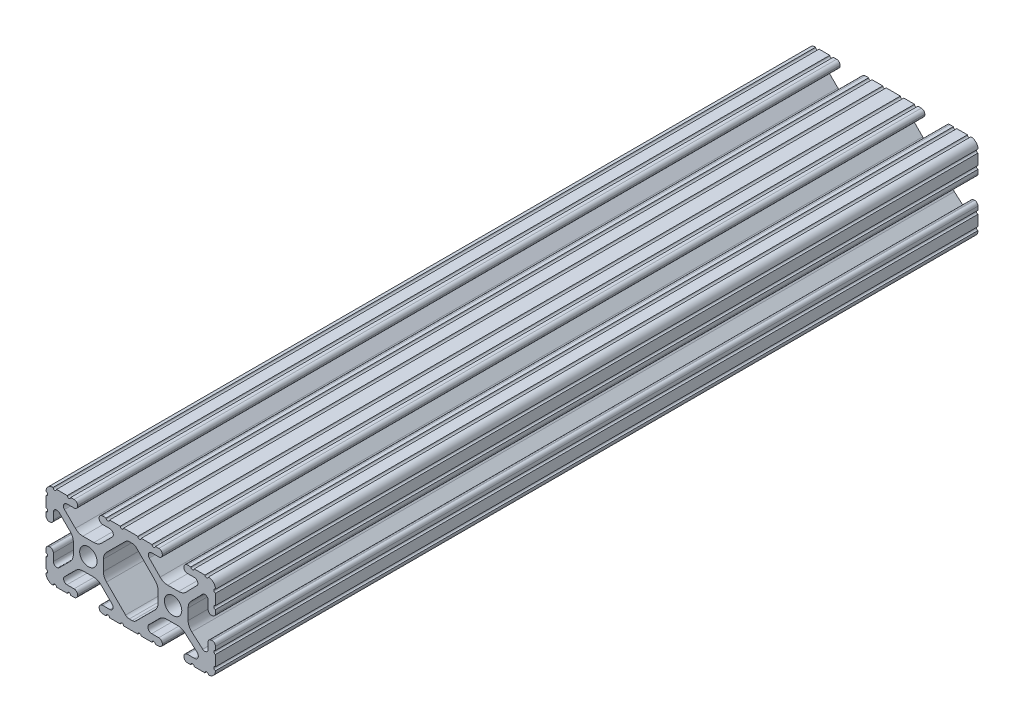
from build123d import *

# Parameters (mm, degrees)
SKETCH1_R           = 2.6035
BOSS_EXTRUDE1_DEPTH = 114.3


with BuildPart() as part:
    # Sketch1 → Boss-Extrude1 (new body, symmetric)
    with BuildSketch(Plane.XY):
        with BuildLine():
            Line((18.01710265, 12.7), (16.98745015, 12.7))
            ThreePointArc((16.98745015, 12.7), (16.245730386, 12.392769614), (15.9385, 11.65104985))
            Line((15.9385, 11.65104985), (15.9385, 11.53922))
            ThreePointArc((15.9385, 11.53922), (16.245750844, 10.797450844), (16.98752, 10.4902))
            Line((16.98752, 10.4902), (19.116384363, 10.4902))
            ThreePointArc((19.116384363, 10.4902), (20.052502933, 9.869096983), (19.844087081, 8.765172272))
            Line((19.844087081, 8.765172272), (16.618993479, 5.455112286))
            ThreePointArc((16.618993479, 5.455112286), (15.578994274, 4.745442459), (14.344932584, 4.4958))
            Line((14.344932584, 4.4958), (11.083317835, 4.4958))
            ThreePointArc((11.083317835, 4.4958), (9.854330953, 4.743306833), (8.816955189, 5.447238587))
            Line((8.816955189, 5.447238587), (5.564154119, 8.762652677))
            ThreePointArc((5.564154119, 8.762652677), (5.352591412, 9.867473037), (6.289393385, 10.4902))
            Line((6.289393385, 10.4902), (8.41248, 10.4902))
            ThreePointArc((8.41248, 10.4902), (9.154249156, 10.797450844), (9.4615, 11.53922))
            Line((9.4615, 11.53922), (9.4615, 11.65104985))
            ThreePointArc((9.4615, 11.65104985), (9.154269614, 12.392769614), (8.41254985, 12.7))
            Line((8.41254985, 12.7), (7.38288465, 12.7))
            ThreePointArc((7.38288465, 12.7), (6.87488465, 12.192), (6.36688465, 12.7))
            Line((6.36688465, 12.7), (3.14958095, 12.7))
            ThreePointArc((3.14958095, 12.7), (2.64158095, 12.192), (2.13358095, 12.7))
            Line((2.13358095, 12.7), (-2.13358095, 12.7))
            ThreePointArc((-2.13358095, 12.7), (-2.64158095, 12.192), (-3.14958095, 12.7))
            Line((-3.14958095, 12.7), (-6.36689735, 12.7))
            ThreePointArc((-6.36689735, 12.7), (-6.87489735, 12.192), (-7.38289735, 12.7))
            Line((-7.38289735, 12.7), (-8.41254985, 12.7))
            ThreePointArc((-8.41254985, 12.7), (-9.154269614, 12.392769614), (-9.4615, 11.65104985))
            Line((-9.4615, 11.65104985), (-9.4615, 11.53922))
            ThreePointArc((-9.4615, 11.53922), (-9.154249156, 10.797450844), (-8.41248, 10.4902))
            Line((-8.41248, 10.4902), (-6.283641037, 10.4902))
            ThreePointArc((-6.283641037, 10.4902), (-5.297291557, 9.829633109), (-5.532576693, 8.666071843))
            Line((-5.532576693, 8.666071843), (-8.809985098, 5.416263103))
            ThreePointArc((-8.809985098, 5.416263103), (-9.836720513, 4.734920264), (-11.045536121, 4.4958))
            Line((-11.045536121, 4.4958), (-14.354463879, 4.4958))
            ThreePointArc((-14.354463879, 4.4958), (-15.563279487, 4.734920264), (-16.590014902, 5.416263103))
            Line((-16.590014902, 5.416263103), (-19.867423307, 8.666071843))
            ThreePointArc((-19.867423307, 8.666071843), (-20.102708443, 9.829633109), (-19.116358963, 10.4902))
            Line((-19.116358963, 10.4902), (-16.98752, 10.4902))
            ThreePointArc((-16.98752, 10.4902), (-16.245750844, 10.797450844), (-15.9385, 11.53922))
            Line((-15.9385, 11.53922), (-15.9385, 11.65104985))
            ThreePointArc((-15.9385, 11.65104985), (-16.245730386, 12.392769614), (-16.98745015, 12.7))
            Line((-16.98745015, 12.7), (-18.01711535, 12.7))
            ThreePointArc((-18.01711535, 12.7), (-18.52511535, 12.192), (-19.03311535, 12.7))
            Line((-19.03311535, 12.7), (-22.2504, 12.7))
            ThreePointArc((-22.2504, 12.7), (-22.758323491, 12.192000006), (-23.266399977, 12.699846982))
            ThreePointArc((-23.266399977, 12.699846982), (-24.782522516, 12.082522516), (-25.399846982, 10.566399977))
            ThreePointArc((-25.399846982, 10.566399977), (-24.892000006, 10.058323491), (-25.4, 9.5504))
            Line((-25.4, 9.5504), (-25.4, 6.3330836))
            ThreePointArc((-25.4, 6.3330836), (-24.892, 5.8250836), (-25.4, 5.3170836))
            Line((-25.4, 5.3170836), (-25.4, 4.237520184))
            ThreePointArc((-25.4, 4.237520184), (-25.107393763, 3.531106237), (-24.400979816, 3.2385))
            Line((-24.400979816, 3.2385), (-24.23922, 3.2385))
            ThreePointArc((-24.23922, 3.2385), (-23.497450844, 3.545750844), (-23.1902, 4.28752))
            Line((-23.1902, 4.28752), (-23.1902, 6.334741132))
            ThreePointArc((-23.1902, 6.334741132), (-22.556026952, 7.286023527), (-21.434002553, 7.066535717))
            Line((-21.434002553, 7.066535717), (-18.147950853, 3.808156468))
            ThreePointArc((-18.147950853, 3.808156468), (-17.452759693, 2.774838327), (-17.208501877, 1.553619571))
            Line((-17.208501877, 1.553619571), (-17.208501877, -1.695179196))
            ThreePointArc((-17.208501877, -1.695179196), (-17.450738657, -2.911536421), (-18.140486065, -3.942289578))
            Line((-18.140486065, -3.942289578), (-21.431579576, -7.227386226))
            ThreePointArc((-21.431579576, -7.227386226), (-22.55444896, -7.449940594), (-23.1902, -6.498002195))
            Line((-23.1902, -6.498002195), (-23.1902, -4.28752))
            ThreePointArc((-23.1902, -4.28752), (-23.497450844, -3.545750844), (-24.23922, -3.2385))
            Line((-24.23922, -3.2385), (-24.35098, -3.2385))
            ThreePointArc((-24.35098, -3.2385), (-25.092749156, -3.545750844), (-25.4, -4.28752))
            Line((-25.4, -4.28752), (-25.4, -5.3171344))
            ThreePointArc((-25.4, -5.3171344), (-24.892, -5.8251344), (-25.4, -6.3331344))
            Line((-25.4, -6.3331344), (-25.4, -9.5504))
            ThreePointArc((-25.4, -9.5504), (-24.892000006, -10.058323491), (-25.399846982, -10.566399977))
            ThreePointArc((-25.399846982, -10.566399977), (-24.782522516, -12.082522516), (-23.266399977, -12.699846982))
            ThreePointArc((-23.266399977, -12.699846982), (-22.758323491, -12.192000006), (-22.2504, -12.7))
            Line((-22.2504, -12.7), (-19.03308995, -12.7))
            ThreePointArc((-19.03308995, -12.7), (-18.52508995, -12.192), (-18.01708995, -12.7))
            Line((-18.01708995, -12.7), (-16.9874692, -12.7))
            ThreePointArc((-16.9874692, -12.7), (-16.245700044, -12.392749156), (-15.9384492, -11.65098))
            Line((-15.9384492, -11.65098), (-15.9384492, -11.53922))
            ThreePointArc((-15.9384492, -11.53922), (-16.245700044, -10.797450844), (-16.9874692, -10.4902))
            Line((-16.9874692, -10.4902), (-19.116358963, -10.4902))
            ThreePointArc((-19.116358963, -10.4902), (-20.055197748, -9.862578342), (-19.834124023, -8.755124678))
            Line((-19.834124023, -8.755124678), (-16.49660751, -5.423689618))
            ThreePointArc((-16.49660751, -5.423689618), (-15.467274017, -4.736928798), (-14.253591699, -4.4958))
            Line((-14.253591699, -4.4958), (-11.146408301, -4.4958))
            ThreePointArc((-11.146408301, -4.4958), (-9.932725983, -4.736928798), (-8.90339249, -5.423689618))
            Line((-8.90339249, -5.423689618), (-5.565875977, -8.755124678))
            ThreePointArc((-5.565875977, -8.755124678), (-5.344802252, -9.862578342), (-6.283641037, -10.4902))
            Line((-6.283641037, -10.4902), (-8.4125308, -10.4902))
            ThreePointArc((-8.4125308, -10.4902), (-9.154299956, -10.797450844), (-9.4615508, -11.53922))
            Line((-9.4615508, -11.53922), (-9.4615508, -11.65098))
            ThreePointArc((-9.4615508, -11.65098), (-9.154299956, -12.392749156), (-8.4125308, -12.7))
            Line((-8.4125308, -12.7), (-7.38287195, -12.7))
            ThreePointArc((-7.38287195, -12.7), (-6.87487195, -12.192), (-6.36687195, -12.7))
            Line((-6.36687195, -12.7), (-3.14960635, -12.7))
            ThreePointArc((-3.14960635, -12.7), (-2.64160635, -12.192), (-2.13360635, -12.7))
            Line((-2.13360635, -12.7), (2.13360635, -12.7))
            ThreePointArc((2.13360635, -12.7), (2.64159365, -12.1920127), (3.14958095, -12.7))
            Line((3.14958095, -12.7), (6.36691005, -12.7))
            ThreePointArc((6.36691005, -12.7), (6.87491005, -12.192), (7.38291005, -12.7))
            Line((7.38291005, -12.7), (8.4125308, -12.7))
            ThreePointArc((8.4125308, -12.7), (9.154299956, -12.392749156), (9.4615508, -11.65098))
            Line((9.4615508, -11.65098), (9.4615508, -11.53922))
            ThreePointArc((9.4615508, -11.53922), (9.154299956, -10.797450844), (8.4125308, -10.4902))
            Line((8.4125308, -10.4902), (6.289393385, -10.4902))
            ThreePointArc((6.289393385, -10.4902), (5.231590322, -9.783049717), (5.480677245, -8.535265862))
            Line((5.480677245, -8.535265862), (8.597933595, -5.423689618))
            ThreePointArc((8.597933595, -5.423689618), (9.627267088, -4.736928798), (10.840949406, -4.4958))
            Line((10.840949406, -4.4958), (14.102564155, -4.4958))
            ThreePointArc((14.102564155, -4.4958), (15.215927525, -4.697410182), (16.187895372, -5.276636531))
            Line((16.187895372, -5.276636531), (19.868247549, -8.482246082))
            ThreePointArc((19.868247549, -8.482246082), (20.188435806, -9.746879864), (19.116384363, -10.4902))
            Line((19.116384363, -10.4902), (16.9874692, -10.4902))
            ThreePointArc((16.9874692, -10.4902), (16.245700044, -10.797450844), (15.9384492, -11.53922))
            Line((15.9384492, -11.53922), (15.9384492, -11.65098))
            ThreePointArc((15.9384492, -11.65098), (16.245700044, -12.392749156), (16.9874692, -12.7))
            Line((16.9874692, -12.7), (18.01710265, -12.7))
            ThreePointArc((18.01710265, -12.7), (18.52510265, -12.192), (19.03310265, -12.7))
            Line((19.03310265, -12.7), (22.2504, -12.7))
            ThreePointArc((22.2504, -12.7), (22.758323491, -12.192000006), (23.266399977, -12.699846982))
            ThreePointArc((23.266399977, -12.699846982), (24.782522516, -12.082522516), (25.399846982, -10.566399977))
            ThreePointArc((25.399846982, -10.566399977), (24.892000006, -10.058323492), (25.4, -9.550400001))
            Line((25.4, -9.550400001), (25.4, -6.333083592))
            ThreePointArc((25.4, -6.333083592), (24.892000001, -5.825083593), (25.4, -5.317083593))
            Line((25.4, -5.317083593), (25.4, -4.237520184))
            ThreePointArc((25.4, -4.237520184), (25.107393763, -3.531106237), (24.400979816, -3.2385))
            Line((24.400979816, -3.2385), (24.189220184, -3.2385))
            ThreePointArc((24.189220184, -3.2385), (23.482806237, -3.531106237), (23.1902, -4.237520184))
            Line((23.1902, -4.237520184), (23.1902, -6.155876159))
            ThreePointArc((23.1902, -6.155876159), (22.62232736, -7.038258539), (21.583974541, -6.886926384))
            Line((21.583974541, -6.886926384), (18.29817066, -4.024970844))
            ThreePointArc((18.29817066, -4.024970844), (17.493730985, -2.946044689), (17.208501877, -1.630807374))
            Line((17.208501877, -1.630807374), (17.208501877, 1.630807374))
            ThreePointArc((17.208501877, 1.630807374), (17.442348332, 2.82673414), (18.109440981, 3.846495088))
            Line((18.109440981, 3.846495088), (21.526346532, 7.353420386))
            ThreePointArc((21.526346532, 7.353420386), (22.585896263, 7.574939077), (23.1902, 6.676867167))
            Line((23.1902, 6.676867167), (23.1902, 4.237520184))
            ThreePointArc((23.1902, 4.237520184), (23.482806237, 3.531106237), (24.189220184, 3.2385))
            Line((24.189220184, 3.2385), (24.400979816, 3.2385))
            ThreePointArc((24.400979816, 3.2385), (25.107393763, 3.531106237), (25.4, 4.237520184))
            Line((25.4, 4.237520184), (25.4, 5.3170836))
            ThreePointArc((25.4, 5.3170836), (24.891949193, 5.825134407), (25.4, 6.333185215))
            Line((25.4, 6.333185215), (25.4, 9.550400015))
            ThreePointArc((25.4, 9.550400015), (24.892000013, 10.058323498), (25.399846982, 10.566399977))
            ThreePointArc((25.399846982, 10.566399977), (24.782522516, 12.082522516), (23.266399977, 12.699846982))
            ThreePointArc((23.266399977, 12.699846982), (22.758323491, 12.192000006), (22.2504, 12.7))
            Line((22.2504, 12.7), (19.03310265, 12.7))
            ThreePointArc((19.03310265, 12.7), (18.52510265, 12.192), (18.01710265, 12.7))
        make_face()
        with Locations((-12.7, 0)):
            Circle(SKETCH1_R, mode=Mode.SUBTRACT)
        with Locations((12.7, 0)):
            Circle(SKETCH1_R, mode=Mode.SUBTRACT)
        with BuildLine():
            Line((-7.259513935, -3.869413038), (-1.545748891, -9.572766749))
            ThreePointArc((-1.545748891, -9.572766749), (-1.035199478, -9.913400116), (-0.433213048, -10.033))
            Line((-0.433213048, -10.033), (0.433213048, -10.033))
            ThreePointArc((0.433213048, -10.033), (1.035199478, -9.913400116), (1.545748891, -9.572766749))
            Line((1.545748891, -9.572766749), (7.259513935, -3.869413038))
            ThreePointArc((7.259513935, -3.869413038), (7.949261343, -2.838659881), (8.191498123, -1.622302656))
            Line((8.191498123, -1.622302656), (8.191498123, 1.622302656))
            ThreePointArc((8.191498123, 1.622302656), (7.955573352, 2.823327967), (7.282860769, 3.845864069))
            Line((7.282860769, 3.845864069), (1.675572808, 9.561086461))
            ThreePointArc((1.675572808, 9.561086461), (1.161034429, 9.910236611), (0.551456936, 10.033))
            Line((0.551456936, 10.033), (-0.395199982, 10.033))
            ThreePointArc((-0.395199982, 10.033), (-0.994772524, 9.914396349), (-1.50403329, 9.576450301))
            Line((-1.50403329, 9.576450301), (-7.252049147, 3.876839553))
            ThreePointArc((-7.252049147, 3.876839553), (-7.947240307, 2.843521412), (-8.191498123, 1.622302656))
            Line((-8.191498123, 1.622302656), (-8.191498123, -1.622302656))
            ThreePointArc((-8.191498123, -1.622302656), (-7.949261343, -2.838659881), (-7.259513935, -3.869413038))
        make_face(mode=Mode.SUBTRACT)
    extrude(amount=BOSS_EXTRUDE1_DEPTH, both=True)


solid = part.part
